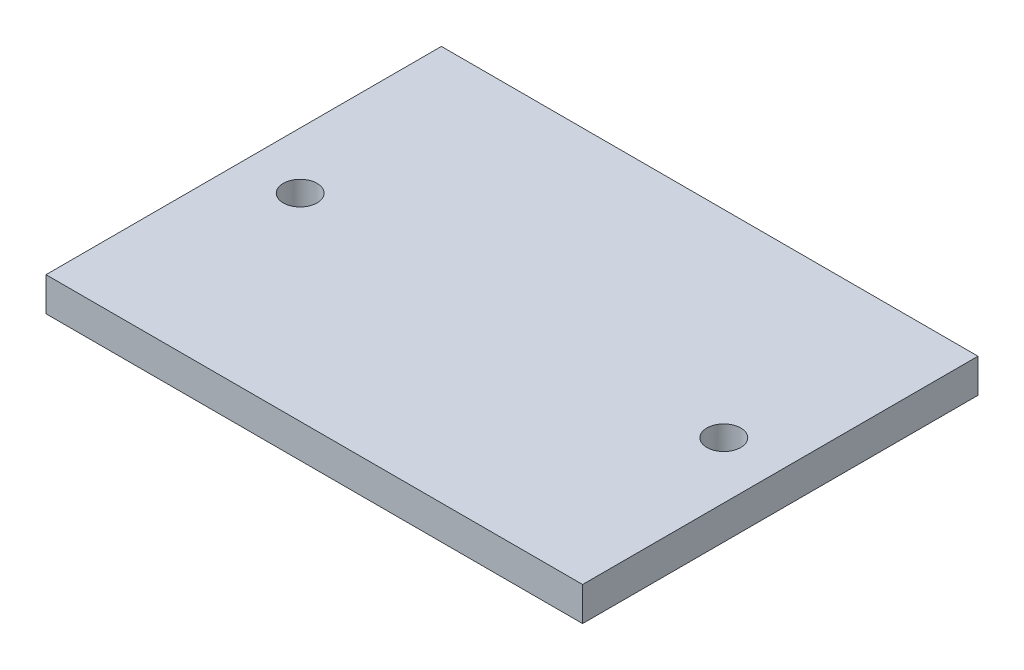
from build123d import *

# Parameters (mm, degrees)
SKETCH2_W                 = 47.5
SKETCH2_H                 = 35
BOSS_EXTRUDE1_DEPTH       = 3
F_3_0MM_DOWEL_HOLE1_D     = 3
F_3_0MM_DOWEL_HOLE1_DEPTH = 3


with BuildPart() as part:
    # Sketch2 → Boss-Extrude1 (new body)
    with BuildSketch(Plane(origin=(0, 0, 0), x_dir=(1, 0, 0), z_dir=(0, 1, 0))):
        with Locations((23.75, 17.5)):
            Rectangle(SKETCH2_W, SKETCH2_H)
    extrude(amount=BOSS_EXTRUDE1_DEPTH)

    # Ø3.0mm Dowel Hole1
    with Locations(Plane(origin=(0, 3, 0), x_dir=(1, 0, 0), z_dir=(0, 1, 0))):
        with Locations((5, 17.5), (42.5, 17.5)):
            Hole(F_3_0MM_DOWEL_HOLE1_D / 2, depth=F_3_0MM_DOWEL_HOLE1_DEPTH)


solid = part.part
